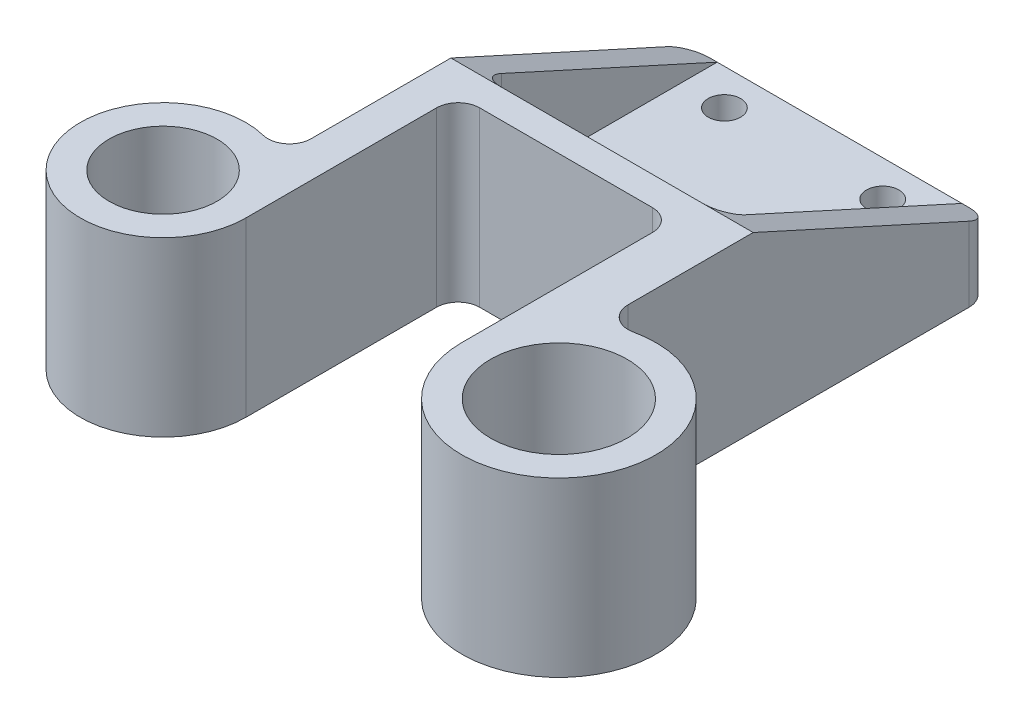
from build123d import *

# Parameters (mm, degrees)
SKETCH1_R               = 2.25
SKETCH1_R_2             = 9.5
SKETCH1_R_3             = 7.5
BOSS_EXTRUDE1_DEPTH     = 24
SKETCH2_W               = 34
SKETCH2_H               = 33
CUT_EXTRUDE1_DEPTH      = 15
CUT_EXTRUDE2_DEPTH      = 59
CUT_EXTRUDE2_DEPTH_BACK = 23
FILLET1_R               = 3


with BuildPart() as part:
    # Sketch1 → Boss-Extrude1 (new body)
    with BuildSketch(Plane(origin=(0, 0, 0), x_dir=(1, 0, 0), z_dir=(0, 1, 0))):
        with BuildLine():
            Line((21, 11.832159566), (21, 66.5))
            Line((21, 66.5), (-21, 66.5))
            Line((-21, 66.5), (-21, 9.486832981))
            ThreePointArc((-21, 9.486832981), (-37.673494975, -5.361902647), (-16, 0))
            Line((-16, 0), (-16, 29.5))
            Line((-16, 29.5), (14, 29.5))
            Line((14, 29.5), (14, 0))
            ThreePointArc((14, 0), (39.118950039, -6.873863542), (21, 11.832159566))
        make_face()
        with Locations((-11, 38.5)):
            Circle(SKETCH1_R, mode=Mode.SUBTRACT)
        with Locations((-11, 61.5)):
            Circle(SKETCH1_R, mode=Mode.SUBTRACT)
        with Locations((11, 61.5)):
            Circle(SKETCH1_R, mode=Mode.SUBTRACT)
        with Locations((11, 38.5)):
            Circle(SKETCH1_R, mode=Mode.SUBTRACT)
        with Locations((27.5, 0)):
            Circle(SKETCH1_R_2, mode=Mode.SUBTRACT)
        with Locations((-27.5, 0)):
            Circle(SKETCH1_R_3, mode=Mode.SUBTRACT)
    extrude(amount=BOSS_EXTRUDE1_DEPTH)

    # Sketch2 → Cut-Extrude1 (cut)
    with BuildSketch(Plane(origin=(0, 24, 0), x_dir=(1, 0, 0), z_dir=(0, 1, 0))):
        with Locations((0, 50)):
            Rectangle(SKETCH2_W, SKETCH2_H)
    extrude(amount=-CUT_EXTRUDE1_DEPTH, mode=Mode.SUBTRACT)

    # Sketch4 → Cut-Extrude2 (cut, two sides)
    with BuildSketch(Plane(origin=(-17, 0, 0), x_dir=(0, 0, -1), z_dir=(1, 0, 0))) as cut_extrude2_sk:
        Polygon((33.5, 24), (66.5, 9), (66.5, 24), align=None)
    extrude(amount=CUT_EXTRUDE2_DEPTH, mode=Mode.SUBTRACT)
    extrude(cut_extrude2_sk.sketch, amount=-CUT_EXTRUDE2_DEPTH_BACK, mode=Mode.SUBTRACT)

    # Fillet1
    fillet1_edges = [part.edges().sort_by_distance(p)[0] for p in [
        (14, 12, -29.5),
        (-16, 12, -29.5),
        (-21, 12, -9.486832981),
        (21, 12, -11.832159566),
        (-17, 16.5, -33.5),
        (17, 16.5, -33.5),
        (-21, 4.5, -66.5),
        (21, 4.5, -66.5),
    ]]
    fillet(fillet1_edges, radius=FILLET1_R)


solid = part.part
